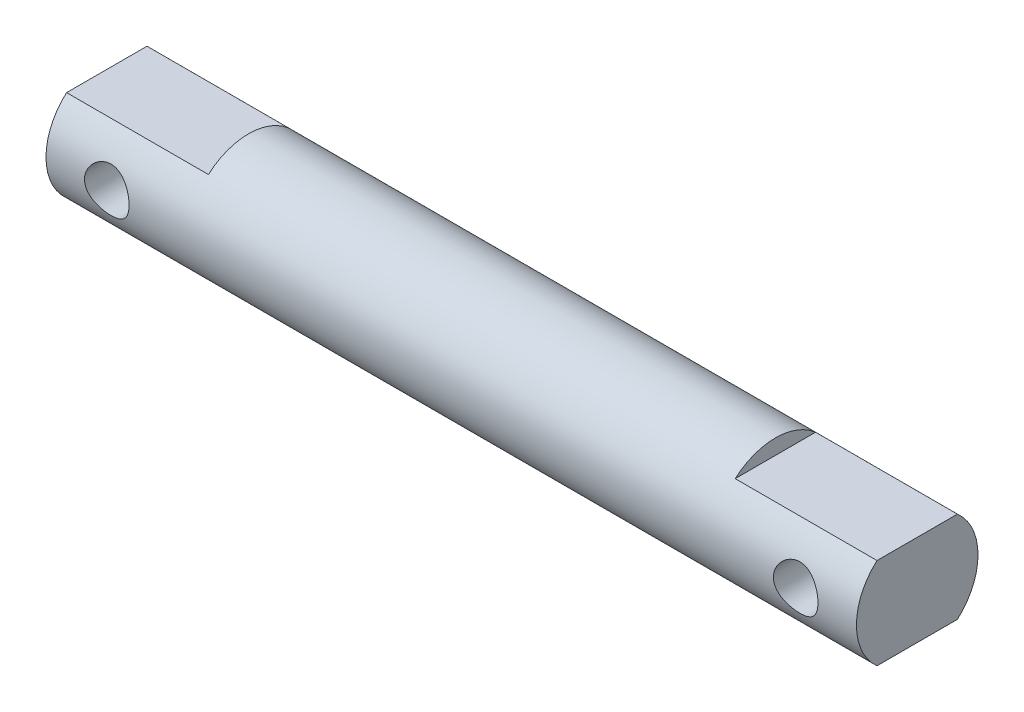
from build123d import *

# Parameters (mm, degrees)
SKETCH1_W               = 40
SKETCH1_H               = 3
SKETCH2_W               = 7
SKETCH2_H               = 0.75
CUT_EXTRUDE1_DEPTH      = 4
CUT_EXTRUDE1_DEPTH_BACK = 4
SKETCH3_R               = 1.1
CUT_EXTRUDE2_DEPTH      = 4
CUT_EXTRUDE2_DEPTH_BACK = 4


with BuildPart() as part:
    # Sketch1 → Revolve1 (revolve)
    with BuildSketch(Plane.XY):
        with Locations((0, 1.5)):
            Rectangle(SKETCH1_W, SKETCH1_H)
    revolve(axis=Axis((0, 0, 0), (1, 0, 0)))

    # Sketch2 → Cut-Extrude1 (cut, two sides)
    with BuildSketch(Plane.XY) as cut_extrude1_sk:
        with Locations((-16.5, 2.625)):
            Rectangle(SKETCH2_W, SKETCH2_H)
        with Locations((-16.5, -2.625)):
            Rectangle(SKETCH2_W, SKETCH2_H)
        with Locations((16.5, 2.625)):
            Rectangle(SKETCH2_W, SKETCH2_H)
        with Locations((16.5, -2.625)):
            Rectangle(SKETCH2_W, SKETCH2_H)
    extrude(amount=CUT_EXTRUDE1_DEPTH, mode=Mode.SUBTRACT)
    extrude(cut_extrude1_sk.sketch, amount=-CUT_EXTRUDE1_DEPTH_BACK, mode=Mode.SUBTRACT)

    # Sketch3 → Cut-Extrude2 (cut, two sides)
    with BuildSketch(Plane.XY) as cut_extrude2_sk:
        with Locations((-17, 0)):
            Circle(SKETCH3_R)
        with Locations((17, 0)):
            Circle(SKETCH3_R)
    extrude(amount=CUT_EXTRUDE2_DEPTH, mode=Mode.SUBTRACT)
    extrude(cut_extrude2_sk.sketch, amount=-CUT_EXTRUDE2_DEPTH_BACK, mode=Mode.SUBTRACT)


solid = part.part
